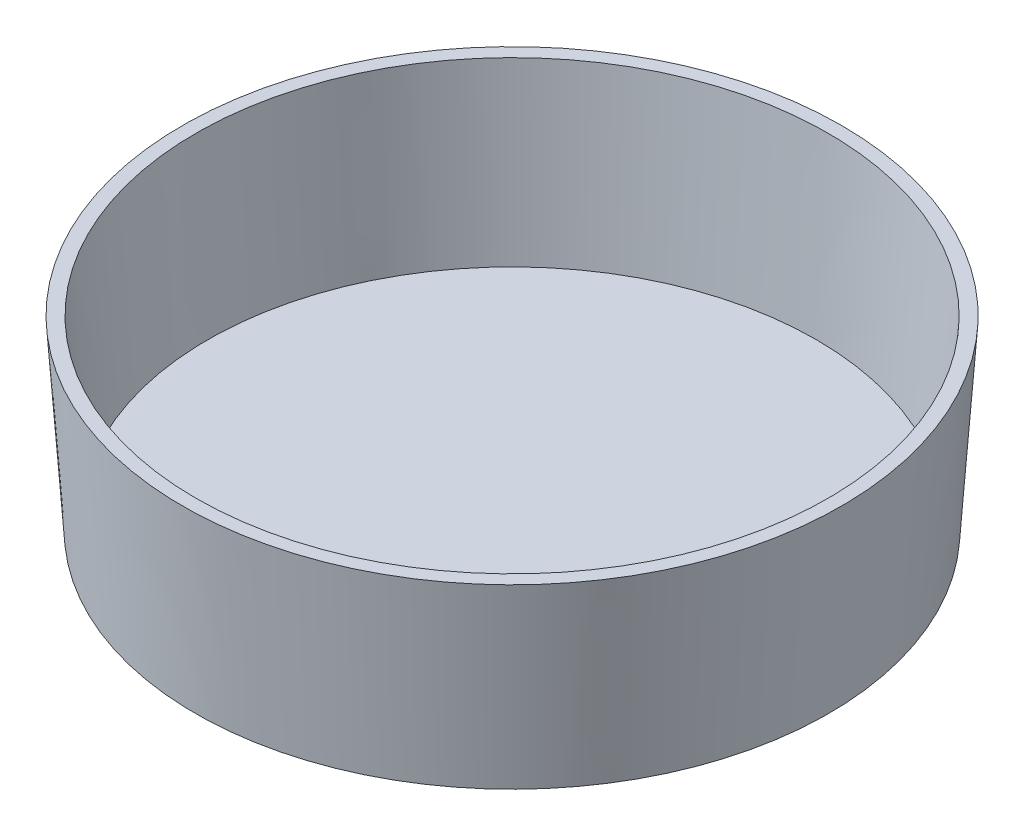
from build123d import *

# Parameters (mm, degrees)
SHELL1_T            = -1.016
SKETCH3_R           = 20.9741
SKETCH3_R_2         = 20.2883
BOSS_EXTRUDE1_DEPTH = 0.762


with BuildPart() as part:
    # Sketch2 → Revolve1 (revolve)
    with BuildSketch(Plane.XY, mode=Mode.PRIVATE) as revolve1_sk:
        Polygon((0, 0), (24.0221, 0), (25, 14.1224), (0, 14.1224), align=None)
    revolve(revolve1_sk.sketch.rotate(Axis((0, 0, 0), (0, 1, 0)), 90), axis=Axis((0, 0, 0), (0, 1, 0)))

    # Shell1
    shell1_openings = [part.faces().sort_by_distance(p)[0] for p in [
        (0, 14.1224, 0),
    ]]
    offset(amount=SHELL1_T, openings=shell1_openings, kind=Kind.INTERSECTION)

    # Sketch3 → Boss-Extrude1 (add)
    with BuildSketch(Plane.XZ):
        with Locations(Location((0, 0, 0), (0, 0, 90))):
            Circle(SKETCH3_R)
        with Locations(Location((0, 0, 0), (0, 0, 90))):
            Circle(SKETCH3_R_2, mode=Mode.SUBTRACT)
    extrude(amount=BOSS_EXTRUDE1_DEPTH)


solid = part.part
